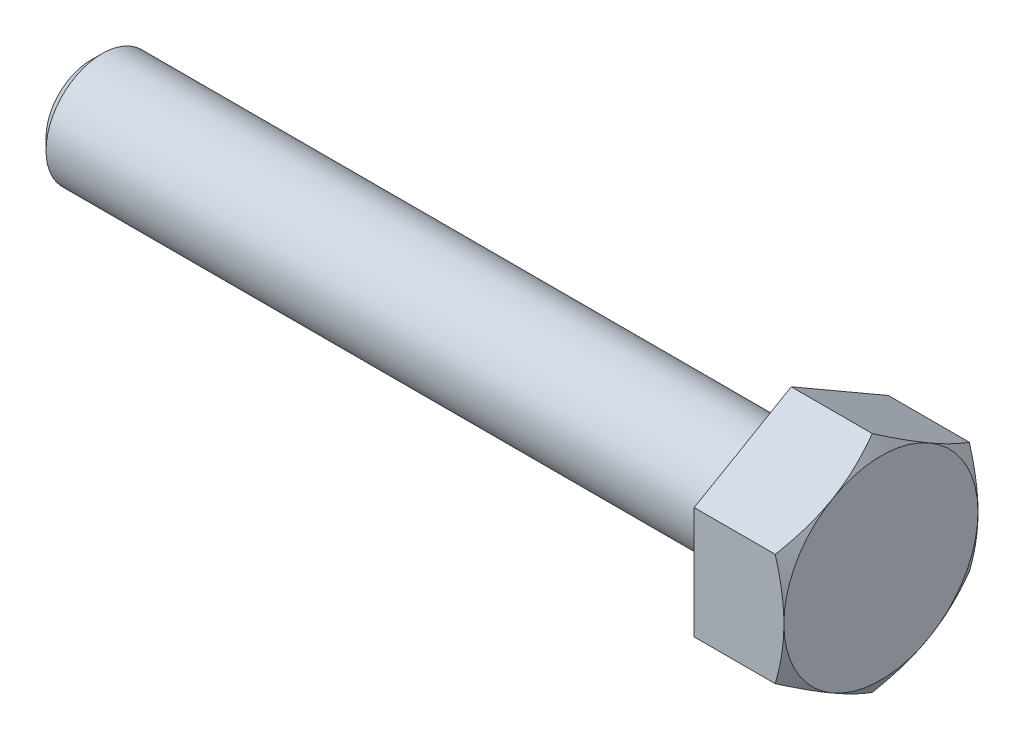
from build123d import *

# Parameters (mm, degrees)
BOSS_EXTRUDE2_DEPTH = 19.2
SKETCH3_R           = 12
BOSS_EXTRUDE3_DEPTH = 150
CHAMFER1_SIZE       = 2.4
SKETCH5_OUTSIDE_W   = 599.33
SKETCH5_OUTSIDE_H   = 605.76
SKETCH5_OUTSIDE_R   = 20.784609691
CUT_EXTRUDE1_DEPTH  = 150
CUT_EXTRUDE1_TAPER  = 60


with BuildPart() as part:
    # Sketch1 → Boss-Extrude2 (new body)
    with BuildSketch(Plane(origin=(0, 0, 0), x_dir=(0, 0, -1), z_dir=(1, 0, 0))):
        Polygon((0, 24), (-20.784609691, 12), (-20.784609691, -12), (0, -24), (20.784609691, -12), (20.784609691, 12), align=None)
    extrude(amount=BOSS_EXTRUDE2_DEPTH)

    # Sketch3 → Boss-Extrude3 (add)
    with BuildSketch(Plane.ZY):
        Circle(SKETCH3_R)
    extrude(amount=BOSS_EXTRUDE3_DEPTH)

    # Chamfer1
    chamfer1_edges = [part.edges().sort_by_distance(p)[0] for p in [
        (-150, 0, -12),
    ]]
    chamfer(chamfer1_edges, length=CHAMFER1_SIZE)

    # Sketch5 outside → Cut-Extrude1 (cut)
    with BuildSketch(Plane(origin=(19.2, 0, 0), x_dir=(0, 0, -1), z_dir=(1, 0, 0))):
        Rectangle(SKETCH5_OUTSIDE_W, SKETCH5_OUTSIDE_H)
        Circle(SKETCH5_OUTSIDE_R, mode=Mode.SUBTRACT)
    extrude(amount=-CUT_EXTRUDE1_DEPTH, taper=CUT_EXTRUDE1_TAPER, mode=Mode.SUBTRACT)


solid = part.part
